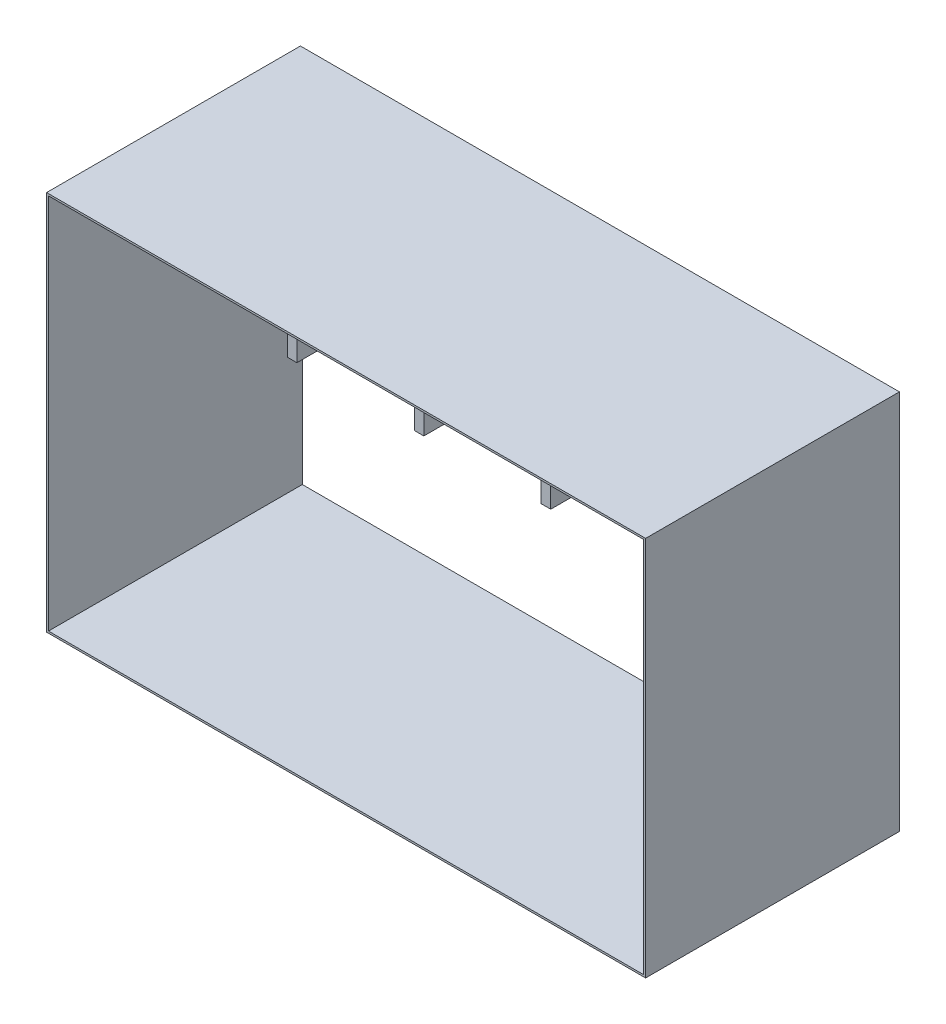
from build123d import *

# Parameters (mm, degrees)
CROQUIS1_W                = 944
CROQUIS1_H                = 600
SALIENTE_EXTRUIR1_DEPTH   = 400
CROQUIS2_W                = 938
CROQUIS2_H                = 594
CORTAR_EXTRUIR1_DEPTH     = 400
CROQUIS3_W                = 15
CROQUIS3_H                = 100
SALIENTE_EXTRUIR2_DEPTH   = 185
SALIENTE_EXTRUIR2_2_DEPTH = 185
SALIENTE_EXTRUIR2_3_DEPTH = 185
SALIENTE_EXTRUIR2_4_DEPTH = 185
CROQUIS5_R                = 8
CORTAR_EXTRUIR2_DEPTH     = 615


with BuildPart() as part:
    # Croquis1 → Saliente-Extruir1 (new body)
    with BuildSketch(Plane.XY):
        Rectangle(CROQUIS1_W, CROQUIS1_H)
    extrude(amount=SALIENTE_EXTRUIR1_DEPTH)

    # Croquis2 → Cortar-Extruir1 (cut)
    with BuildSketch(Plane.XY.offset(400)):
        Rectangle(CROQUIS2_W, CROQUIS2_H)
    extrude(amount=-CORTAR_EXTRUIR1_DEPTH, mode=Mode.SUBTRACT)


with BuildPart() as body_2:
    # Croquis3 → Saliente-Extruir2 (new body)
    with BuildSketch(Plane(origin=(0, 0, 0), x_dir=(-1, 0, 0), z_dir=(0, 0, -1))):
        with Locations((-300, 100)):
            Rectangle(CROQUIS3_W, CROQUIS3_H)
    extrude(amount=-SALIENTE_EXTRUIR2_DEPTH)


with BuildPart() as body_3:
    # Croquis3 → Saliente-Extruir2 2 (new body)
    with BuildSketch(Plane(origin=(0, 0, 0), x_dir=(-1, 0, 0), z_dir=(0, 0, -1))):
        with Locations((-100, 100)):
            Rectangle(CROQUIS3_W, CROQUIS3_H)
    extrude(amount=-SALIENTE_EXTRUIR2_2_DEPTH)


with BuildPart() as body_4:
    # Croquis3 → Saliente-Extruir2 3 (new body)
    with BuildSketch(Plane(origin=(0, 0, 0), x_dir=(-1, 0, 0), z_dir=(0, 0, -1))):
        with Locations((100, 100)):
            Rectangle(CROQUIS3_W, CROQUIS3_H)
    extrude(amount=-SALIENTE_EXTRUIR2_3_DEPTH)


with BuildPart() as body_5:
    # Croquis3 → Saliente-Extruir2 4 (new body)
    with BuildSketch(Plane(origin=(0, 0, 0), x_dir=(-1, 0, 0), z_dir=(0, 0, -1))):
        with Locations((300, 100)):
            Rectangle(CROQUIS3_W, CROQUIS3_H)
    extrude(amount=-SALIENTE_EXTRUIR2_4_DEPTH)


with BuildPart() as cortar_extruir2_tool:
    # Croquis5 → Cortar-Extruir2 (new body)
    with BuildSketch(Plane.ZY.offset(307.5)):
        with Locations((155, 122)):
            Circle(CROQUIS5_R)
        with Locations((155, 78)):
            Circle(CROQUIS5_R)
        with Locations((110, 122)):
            Circle(CROQUIS5_R)
        with Locations((110, 78)):
            Circle(CROQUIS5_R)
    extrude(amount=-CORTAR_EXTRUIR2_DEPTH)


with BuildPart() as body_2_1:
    add(body_2.part)

    # Cortar-Extruir2: cut by cortar_extruir2_tool
    add(cortar_extruir2_tool.part, mode=Mode.SUBTRACT)


with BuildPart() as body_3_1:
    add(body_3.part)

    # Cortar-Extruir2: cut by cortar_extruir2_tool
    add(cortar_extruir2_tool.part, mode=Mode.SUBTRACT)


with BuildPart() as body_4_1:
    add(body_4.part)

    # Cortar-Extruir2: cut by cortar_extruir2_tool
    add(cortar_extruir2_tool.part, mode=Mode.SUBTRACT)


with BuildPart() as body_5_1:
    add(body_5.part)

    # Cortar-Extruir2: cut by cortar_extruir2_tool
    add(cortar_extruir2_tool.part, mode=Mode.SUBTRACT)


solid = Compound([part.part, body_2_1.part, body_3_1.part, body_4_1.part, body_5_1.part])
